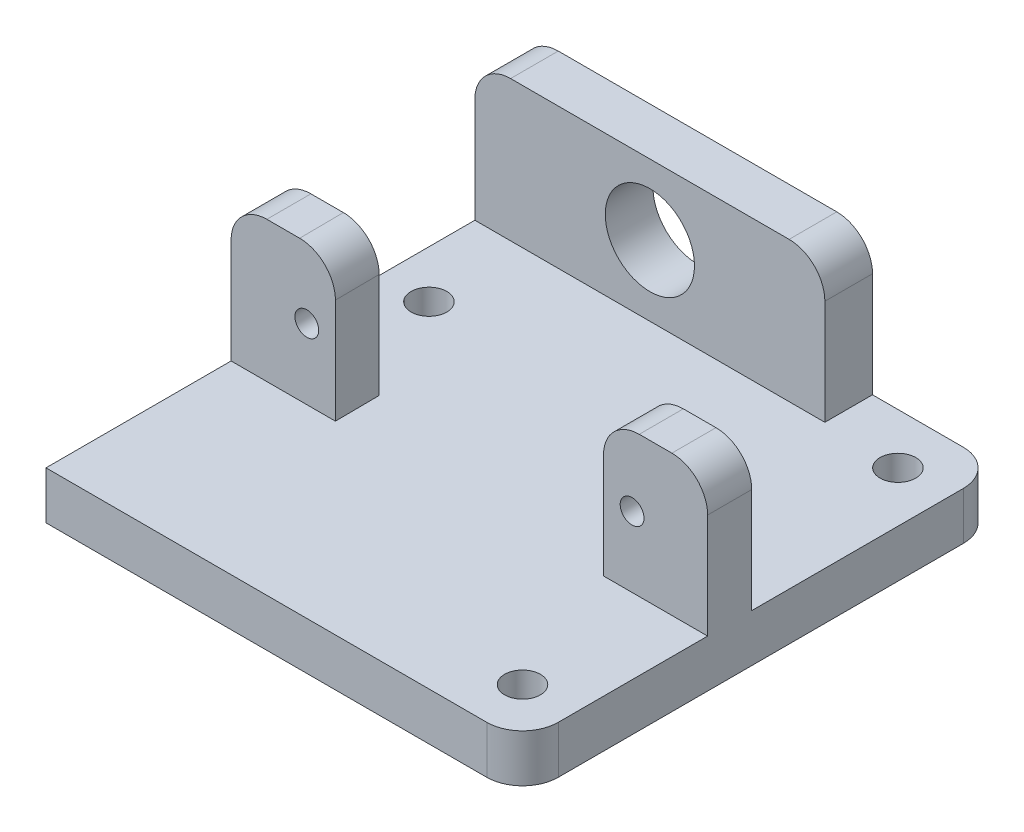
from build123d import *

# Parameters (mm, degrees)
SKETCH1_W           = 40
SKETCH1_H           = 40
BOSS_EXTRUDE1_DEPTH = 4
SKETCH2_W           = 8.739547094
SKETCH2_H           = 3.7
BOSS_EXTRUDE2_DEPTH = 11.8
BOSS_EXTRUDE3_DEPTH = 11.8
SKETCH4_R           = 3.745
CUT_EXTRUDE1_DEPTH  = 5
SKETCH5_R           = 1
CUT_EXTRUDE2_DEPTH  = 3.7
SKETCH6_R           = 1.5
CUT_EXTRUDE3_DEPTH  = 5
FILLET1_R           = 3
FILLET2_R           = 3


with BuildPart() as part:
    # Sketch1 → Boss-Extrude1 (new body)
    with BuildSketch(Plane(origin=(0, 0, 0), x_dir=(1, 0, 0), z_dir=(0, 1, 0))):
        Rectangle(SKETCH1_W, SKETCH1_H)
    extrude(amount=BOSS_EXTRUDE1_DEPTH)

    # Sketch2 → Boss-Extrude2 (add)
    with BuildSketch(Plane(origin=(0, 4, 0), x_dir=(1, 0, 0), z_dir=(0, 1, 0))):
        Polygon((-20, -0.761716699), (-11.276069587, -0.761716699), (-11.244836225, -4.461716699), (-20, -4.461716699), align=None)
        with Locations((15.630226453, -2.611716699)):
            Rectangle(SKETCH2_W, SKETCH2_H)
    extrude(amount=BOSS_EXTRUDE2_DEPTH)

    # Sketch3 → Boss-Extrude3 (add)
    with BuildSketch(Plane(origin=(0, 4, 0), x_dir=(1, 0, 0), z_dir=(0, 1, 0))):
        Polygon((9.38, 16), (-5.31, 16), (-20, 16), (-20, 20), (-5.31, 20), (9.38, 20), align=None)
    extrude(amount=BOSS_EXTRUDE3_DEPTH)

    # Sketch4 → Cut-Extrude1 (cut, through all)
    with BuildSketch(Plane.XY.offset(-16)):
        with Locations((-5.31, 9.9)):
            Circle(SKETCH4_R)
    extrude(amount=-CUT_EXTRUDE1_DEPTH, mode=Mode.SUBTRACT)

    # Sketch5 → Cut-Extrude2 (cut)
    with BuildSketch(Plane.XY.offset(4.461716699)):
        with Locations((-13.644836225, 9.9)):
            Circle(SKETCH5_R)
        with Locations((13.660452906, 9.9)):
            Circle(SKETCH5_R)
    extrude(amount=-CUT_EXTRUDE2_DEPTH, mode=Mode.SUBTRACT)

    # Sketch6 → Cut-Extrude3 (cut, through all)
    with BuildSketch(Plane(origin=(0, 4, 0), x_dir=(1, 0, 0), z_dir=(0, 1, 0))):
        with Locations((15.757359313, 15.757359313)):
            Circle(SKETCH6_R)
        with Locations((15.757359313, -15.757359313)):
            Circle(SKETCH6_R)
        with Locations((-16, 8.145789662)):
            Circle(SKETCH6_R)
    extrude(amount=-CUT_EXTRUDE3_DEPTH, mode=Mode.SUBTRACT)

    # Fillet1
    fillet1_edges = [part.edges().sort_by_distance(p)[0] for p in [
        (-11.260452906, 15.8, 2.611716699),
        (-20, 15.8, 2.611716699),
        (20, 15.8, 2.611716699),
        (11.260452906, 15.8, 2.611716699),
        (9.38, 15.8, -18),
        (-20, 15.8, -18),
    ]]
    fillet(fillet1_edges, radius=FILLET1_R)

    # Fillet2
    fillet2_edges = [part.edges().sort_by_distance(p)[0] for p in [
        (20, 2, 20),
        (20, 2, -20),
    ]]
    fillet(fillet2_edges, radius=FILLET2_R)


solid = part.part
